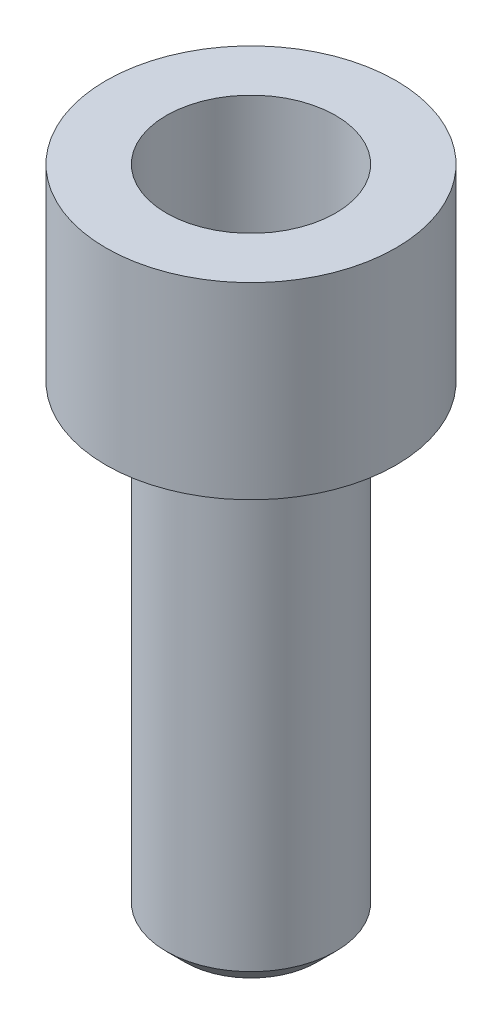
from build123d import *


with BuildPart() as part:
    # Croquis1 → Revolución2 (revolve)
    with BuildSketch(Plane.XY):
        Polygon((0, 15.288089413), (0, -12.590191281), (3.5, -12.590191281), (4.5, -11.590191281), (4.5, 12.409808719), (7.710064991, 12.409808719), (7.710064991, 22.409808719), (4.5, 22.409808719), (4.5, 15.288089413), align=None)
    revolve(axis=Axis((0, 27.379677105, 0), (0, -1, 0)))


solid = part.part
